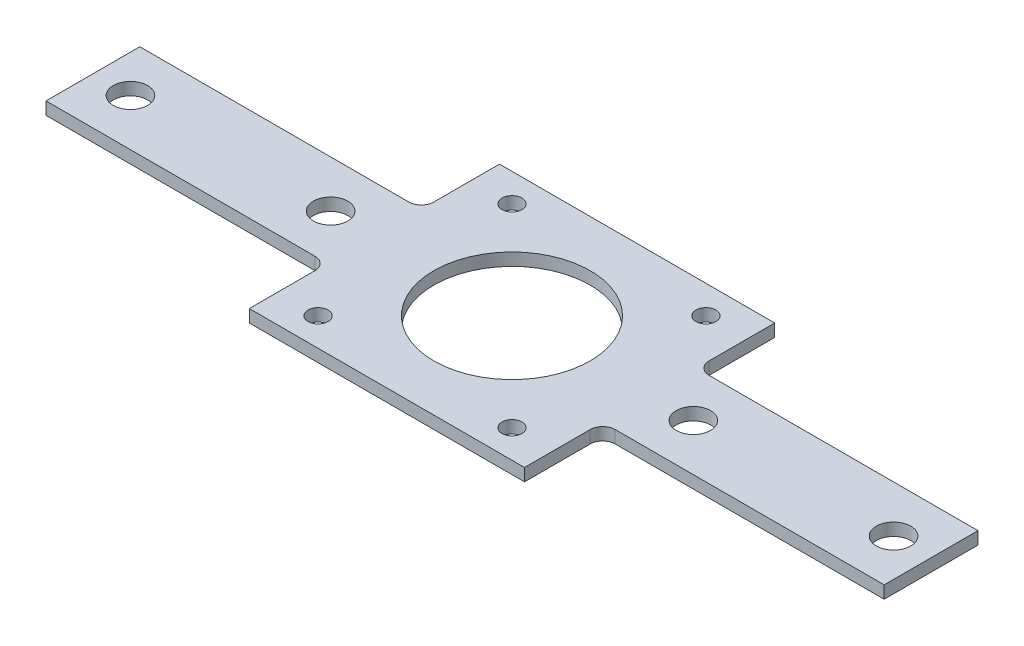
from build123d import *

# Parameters (mm, degrees)
ESQUISSE1_W             = 140
ESQUISSE1_H             = 40
ESQUISSE1_R             = 2.75
ESQUISSE1_R_2           = 1.6
ESQUISSE1_R_3           = 12.5
BOSS_EXTRU_1_DEPTH      = 2
ENL_V_MAT_EXTRU_1_REACH = 4
CONG_1_R                = 2


with BuildPart() as part:
    # Esquisse1 → Boss.-Extru.1 (new body)
    with BuildSketch(Plane(origin=(0, 0, 0), x_dir=(1, 0, 0), z_dir=(0, 1, 0))):
        Rectangle(ESQUISSE1_W, ESQUISSE1_H)
        with Locations((-61, 0)):
            Circle(ESQUISSE1_R, mode=Mode.SUBTRACT)
        with Locations((-29, 0)):
            Circle(ESQUISSE1_R, mode=Mode.SUBTRACT)
        with Locations((29, 0)):
            Circle(ESQUISSE1_R, mode=Mode.SUBTRACT)
        with Locations((61, 0)):
            Circle(ESQUISSE1_R, mode=Mode.SUBTRACT)
        with Locations((-15.5, 15.5)):
            Circle(ESQUISSE1_R_2, mode=Mode.SUBTRACT)
        with Locations((15.5, 15.5)):
            Circle(ESQUISSE1_R_2, mode=Mode.SUBTRACT)
        with Locations((15.5, -15.5)):
            Circle(ESQUISSE1_R_2, mode=Mode.SUBTRACT)
        with Locations((-15.5, -15.5)):
            Circle(ESQUISSE1_R_2, mode=Mode.SUBTRACT)
        Circle(ESQUISSE1_R_3, mode=Mode.SUBTRACT)
    extrude(amount=BOSS_EXTRU_1_DEPTH)

    # Esquisse2 → Enlèv. mat.-Extru.1 (cut, up to next)
    with BuildSketch(Plane.XZ, mode=Mode.PRIVATE) as enl_v_mat_extru_1_sk1:
        Polygon((22, -20), (22, -7.5), (67, -7.5), (67, 7.5), (22, 7.5), (22, 20), (70, 20), (70, -20), align=None)
    enl_v_mat_extru_1_tool1 = extrude(enl_v_mat_extru_1_sk1.sketch, amount=-ENL_V_MAT_EXTRU_1_REACH, mode=Mode.PRIVATE) & part.part
    add(enl_v_mat_extru_1_tool1.solids().sort_by_distance((22.62482, 0, -13.75))[0], mode=Mode.SUBTRACT)
    # Esquisse2 → Enlèv. mat.-Extru.1 (cut, up to next)
    with BuildSketch(Plane.XZ, mode=Mode.PRIVATE) as enl_v_mat_extru_1_sk2:
        Polygon((-70, 20), (-70, -20), (-22, -20), (-22, -7.5), (-67, -7.5), (-67, 7.5), (-22, 7.5), (-22, 20), align=None)
    enl_v_mat_extru_1_tool2 = extrude(enl_v_mat_extru_1_sk2.sketch, amount=-ENL_V_MAT_EXTRU_1_REACH, mode=Mode.PRIVATE) & part.part
    add(enl_v_mat_extru_1_tool2.solids().sort_by_distance((-69.37518, 0, 0))[0], mode=Mode.SUBTRACT)

    # Congé1
    cong_1_edges = [part.edges().sort_by_distance(p)[0] for p in [
        (22, 1, -7.5),
        (22, 1, 7.5),
        (-22, 1, 7.5),
        (-22, 1, -7.5),
    ]]
    fillet(cong_1_edges, radius=CONG_1_R)


solid = part.part
